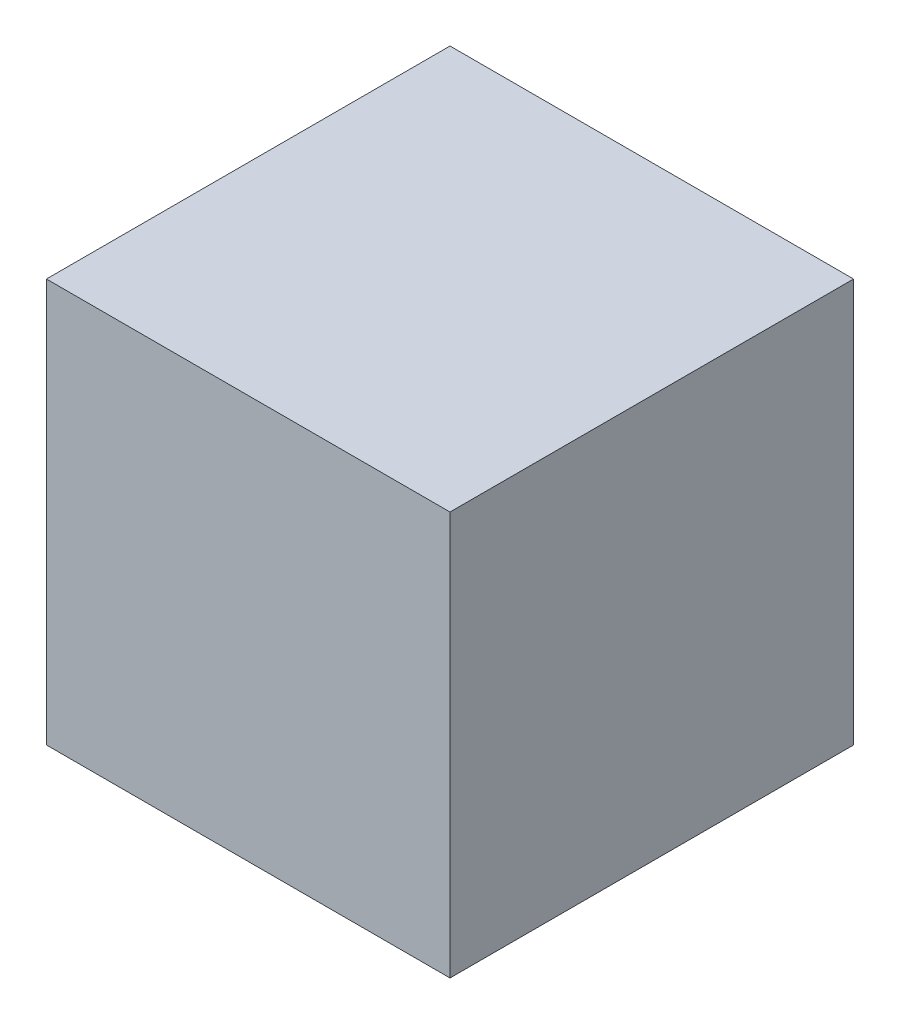
from build123d import *

# Parameters (mm, degrees)
SKETCH1_W      = 304.8
SKETCH1_H      = 304.8
EXTRUDE1_DEPTH = 304.8


with BuildPart() as part:
    # Sketch1 → Extrude1 (new body)
    with BuildSketch(Plane(origin=(0, 0, 0), x_dir=(1, 0, 0), z_dir=(0, 1, 0))):
        with Locations((152.4, 152.4)):
            Rectangle(SKETCH1_W, SKETCH1_H)
    extrude(amount=EXTRUDE1_DEPTH)


solid = part.part
